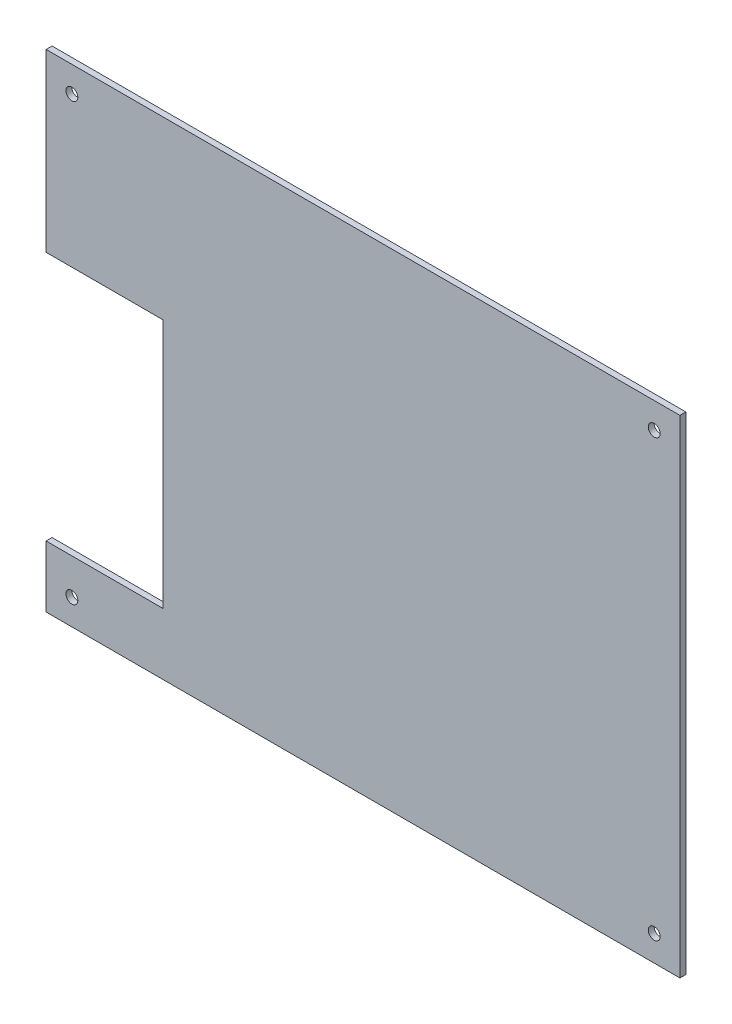
from build123d import *

# Parameters (mm, degrees)
SKETCH_1_W          = 1600
SKETCH_1_H          = 1230
SKETCH_1_R          = 15
EXTRUDE_1_DEPTH     = 3
SCALE_1_SCALE_X     = 0.1
SCALE_1_SCALE_Y     = 0.1
SCALE_1_SCALE_Z     = 0.5
SKETCH_2_W          = 29.5
SKETCH_2_H          = 63.1
CUT_EXTRUDE_1_DEPTH = 2.5000001


with BuildPart() as part:
    # 草图1 → 凸台-拉伸1 (new body)
    with BuildSketch(Plane.XY):
        with Locations((1152.60835314, -1687.80288964)):
            Rectangle(SKETCH_1_W, SKETCH_1_H)
        with Locations((417.60835314, -1137.80288964)):
            Circle(SKETCH_1_R, mode=Mode.SUBTRACT)
        with Locations((1887.60835314, -1137.80288964)):
            Circle(SKETCH_1_R, mode=Mode.SUBTRACT)
        with Locations((1887.60835314, -2237.80288964)):
            Circle(SKETCH_1_R, mode=Mode.SUBTRACT)
        with Locations((417.60835314, -2237.80288964)):
            Circle(SKETCH_1_R, mode=Mode.SUBTRACT)
    extrude(amount=EXTRUDE_1_DEPTH)


with BuildPart() as part_1:
    # 缩放比例1: scaled about (1152.60835314, -1687.80288964, 1.5)
    add(part.part.scale((SCALE_1_SCALE_X, SCALE_1_SCALE_Y, SCALE_1_SCALE_Z), about=(1152.60835314, -1687.80288964, 1.5)))

    # 草图2 → 切除-拉伸1 (cut, through all)
    with BuildSketch(Plane.XY.offset(2.25)):
        with Locations((1087.35835314, -1702.21288964)):
            Rectangle(SKETCH_2_W, SKETCH_2_H)
    extrude(amount=-CUT_EXTRUDE_1_DEPTH, mode=Mode.SUBTRACT)


solid = part_1.part
